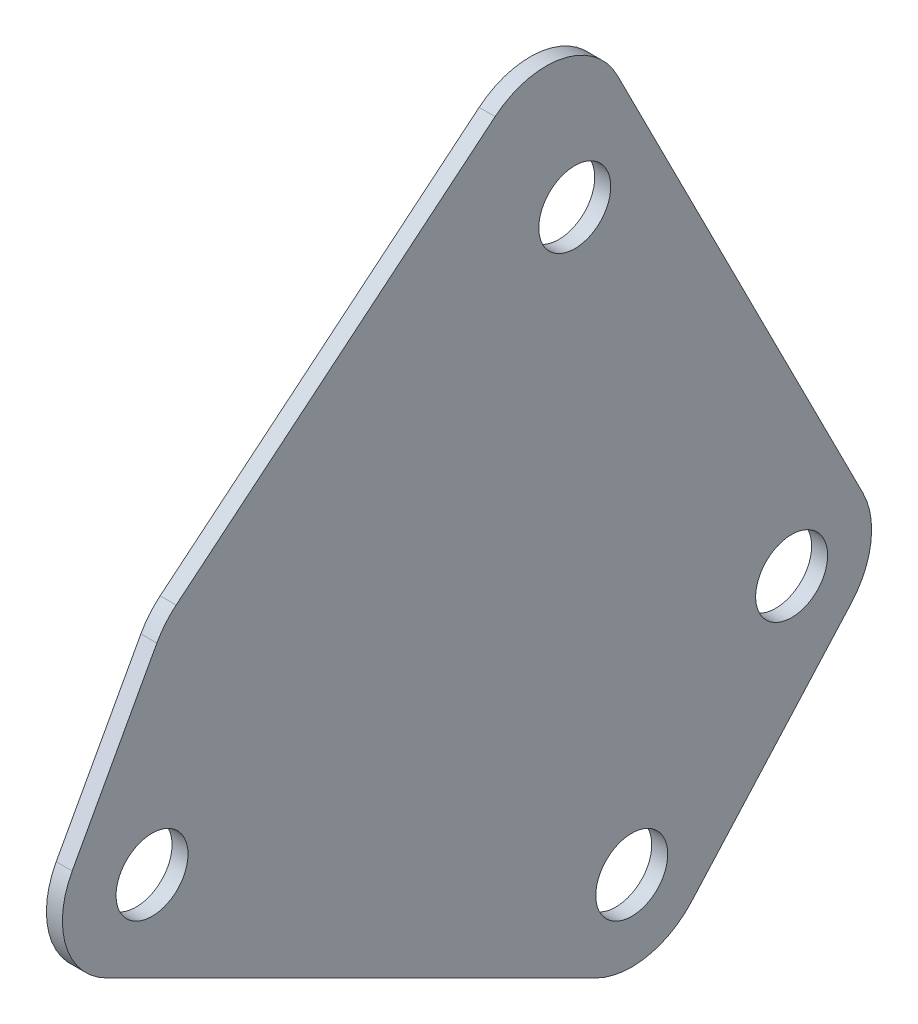
from build123d import *

# Parameters (mm, degrees)
SKETCH1_R           = 2.25
BOSS_EXTRUDE1_DEPTH = 0.5


with BuildPart() as part:
    # Sketch1 → Boss-Extrude1 (new body, symmetric)
    with BuildSketch(Plane(origin=(0, 0, 0), x_dir=(0, 0, -1), z_dir=(1, 0, 0))):
        with BuildLine():
            Line((-2.842316383, -4.169011752), (27.763932023, -19.472135955))
            ThreePointArc((27.763932023, -19.472135955), (30.93796237, -19.911234732), (33.726779962, -18.333333333))
            Line((33.726779962, -18.333333333), (43.726779962, -7.152993446))
            ThreePointArc((43.726779962, -7.152993446), (44.957632334, -4.469184277), (44.459693025, -1.558877478))
            Line((44.459693025, -1.558877478), (29.09925887, 28.74161228))
            ThreePointArc((29.09925887, 28.74161228), (25.660151825, 31.375561942), (21.454986898, 30.335496549))
            Line((21.454986898, 30.335496549), (1.506318758, 13.854666903))
            ThreePointArc((1.506318758, 13.854666903), (0.835117993, 13.183231504), (0.302931344, 12.397029665))
            Line((0.302931344, 12.397029665), (-4.994214766, 2.700153867))
            ThreePointArc((-4.994214766, 2.700153867), (-5.377602176, -1.19159423), (-2.842316383, -4.169011752))
        make_face()
        with Locations((30, -15)):
            Circle(SKETCH1_R, mode=Mode.SUBTRACT)
        with Locations((40, -3.819660113)):
            Circle(SKETCH1_R, mode=Mode.SUBTRACT)
        Circle(SKETCH1_R, mode=Mode.SUBTRACT)
        with Locations((26.435304192, 22.938498039)):
            Circle(SKETCH1_R, mode=Mode.SUBTRACT)
    extrude(amount=BOSS_EXTRUDE1_DEPTH, both=True)


solid = part.part
